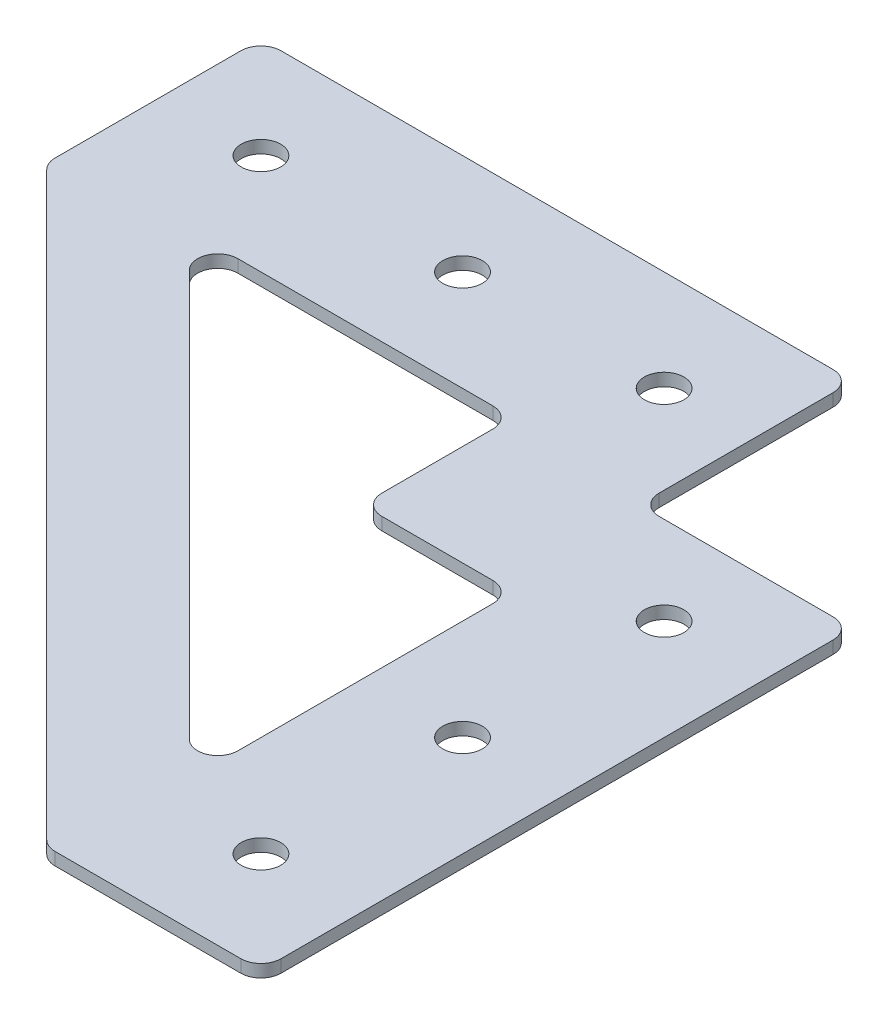
from build123d import *

# Parameters (mm, degrees)
BOSS_EXTRUDE1_DEPTH = 1.5875
FILLET1_R           = 2.54
SKETCH2_R           = 2.4892
CUT_EXTRUDE1_DEPTH  = 2.5875
LPATTERN1_COUNT     = 3
LPATTERN1_PITCH     = 25.4
LPATTERN2_COUNT     = 3
LPATTERN2_PITCH     = 25.4


with BuildPart() as part:
    # Sketch1 → Boss-Extrude1 (new body)
    with BuildSketch(Plane(origin=(0, 0, 0), x_dir=(1, 0, 0), z_dir=(0, 1, 0))):
        Polygon((0, -26.9875), (-26.9875, -26.9875), (-26.9875, 0), (-101.6, 0), (-101.6, -26.9875), (-26.9875, -101.6), (0, -101.6), align=None)
        Polygon((-85.226987758, -25.4), (-25.4, -85.226987758), (-25.4, -44.45), (-44.45, -44.45), (-44.45, -25.4), align=None, mode=Mode.SUBTRACT)
    extrude(amount=BOSS_EXTRUDE1_DEPTH)

    # Fillet1
    fillet1_edges = [part.edges().sort_by_distance(p)[0] for p in [
        (-26.9875, 0.79375, 26.9875),
        (0, 0.79375, 26.9875),
        (0, 0.79375, 101.6),
        (-26.9875, 0.79375, 101.6),
        (-101.6, 0.79375, 26.9875),
        (-101.6, 0.79375, 0),
        (-26.9875, 0.79375, 0),
        (-44.45, 0.79375, 25.4),
        (-85.226987758, 0.79375, 25.4),
        (-25.4, 0.79375, 85.226987758),
        (-25.4, 0.79375, 44.45),
        (-44.45, 0.79375, 44.45),
    ]]
    fillet(fillet1_edges, radius=FILLET1_R)

    # Sketch2 → Cut-Extrude1 (cut, through all)
    with BuildSketch(Plane(origin=(0, 1.5875, 0), x_dir=(1, 0, 0), z_dir=(0, 1, 0))):
        with Locations((-88.9, -12.7)):
            Circle(SKETCH2_R)
        with Locations((-12.7, -88.9)):
            Circle(SKETCH2_R)
    cut_extrude1 = extrude(amount=-CUT_EXTRUDE1_DEPTH, mode=Mode.SUBTRACT)

    # LPattern1: Cut-Extrude1 ×3
    with Locations(*[(i * LPATTERN1_PITCH, 0, 0) for i in range(1, LPATTERN1_COUNT)]):
        add(cut_extrude1, mode=Mode.SUBTRACT)

    # LPattern2: Cut-Extrude1 ×3
    with Locations(*[(0, 0, -i * LPATTERN2_PITCH) for i in range(1, LPATTERN2_COUNT)]):
        add(cut_extrude1, mode=Mode.SUBTRACT)


solid = part.part
